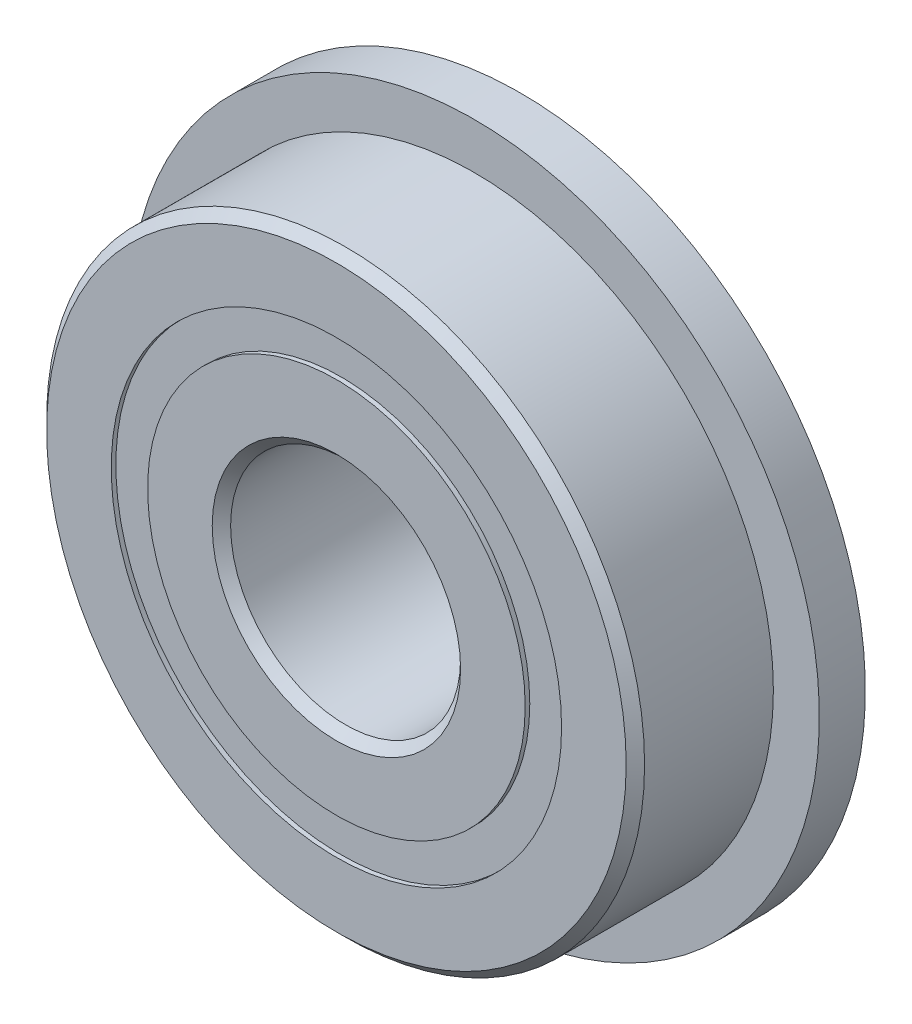
from build123d import *

# Parameters (mm, degrees)
CIRPATTERN1_COUNT = 12
SKETCH5_W         = 0.927052779
SKETCH5_H         = 0.791208792
SKETCH6_W         = 1
SKETCH6_H         = 2.604395604


with BuildPart() as part:
    # Sketch1 → Revolve1 (revolve)
    with BuildSketch(Plane(origin=(0, 0, 0), x_dir=(0, 0, -1), z_dir=(1, 0, 0))):
        with BuildLine():
            Line((1.8, 6.5), (-1.8, 6.5))
            Line((-1.8, 6.5), (-2, 6.3))
            Line((-2, 6.3), (-2, 4.895604396))
            Line((-2, 4.895604396), (-0.888888889, 4.895604396))
            ThreePointArc((-0.888888889, 4.895604396), (0, 5.472947221), (0.888888889, 4.895604396))
            Line((0.888888889, 4.895604396), (2, 4.895604396))
            Line((2, 4.895604396), (2, 6.3))
            Line((2, 6.3), (1.8, 6.5))
        make_face()
    revolve(axis=Axis((0, 0, 2), (0, 0, -1)))

    # Sketch6 → Revolve6 (revolve)
    with BuildSketch(Plane(origin=(0, 0, 0), x_dir=(0, 0, -1), z_dir=(1, 0, 0))):
        with Locations((1.5, 6.197802198)):
            Rectangle(SKETCH6_W, SKETCH6_H)
    revolve(axis=Axis((0, 0, -2), (0, 0, 1)))


with BuildPart() as body_2:
    # Sketch3 → Revolve3 (revolve)
    with BuildSketch(Plane(origin=(0, 0, 0), x_dir=(0, 0, -1), z_dir=(1, 0, 0))):
        with BuildLine():
            Line((-2, 4.104395604), (-0.888888889, 4.104395604))
            ThreePointArc((-0.888888889, 4.104395604), (0, 3.527052779), (0.888888889, 4.104395604))
            Line((0.888888889, 4.104395604), (2, 4.104395604))
            Line((2, 4.104395604), (2, 2.7))
            Line((2, 2.7), (1.8, 2.5))
            Line((1.8, 2.5), (-1.8, 2.5))
            Line((-1.8, 2.5), (-2, 2.7))
            Line((-2, 2.7), (-2, 4.104395604))
        make_face()
    revolve(axis=Axis((0, 0, 2), (0, 0, -1)))


with BuildPart() as body_3:
    # Sketch4 → Revolve4 (revolve)
    with BuildSketch(Plane(origin=(0, 0, 0), x_dir=(0, 0, -1), z_dir=(1, 0, 0))):
        with BuildLine():
            Line((-0.972947221, 4.5), (0.972947221, 4.5))
            ThreePointArc((0.972947221, 4.5), (0, 5.472947221), (-0.972947221, 4.5))
        make_face()
    revolve(axis=Axis((0, 4.5, 0.972947221), (0, 0, -1)))


with BuildPart() as cirpattern1_1:
    # CirPattern1: pattern copy
    add(body_3.part.rotate(Axis((0, 0, 0), (0, 0, 1)), 1 * 360 / CIRPATTERN1_COUNT))


with BuildPart() as cirpattern1_2:
    # CirPattern1: pattern copy
    add(body_3.part.rotate(Axis((0, 0, 0), (0, 0, 1)), 2 * 360 / CIRPATTERN1_COUNT))


with BuildPart() as cirpattern1_3:
    # CirPattern1: pattern copy
    add(body_3.part.rotate(Axis((0, 0, 0), (0, 0, 1)), 3 * 360 / CIRPATTERN1_COUNT))


with BuildPart() as cirpattern1_4:
    # CirPattern1: pattern copy
    add(body_3.part.rotate(Axis((0, 0, 0), (0, 0, 1)), 4 * 360 / CIRPATTERN1_COUNT))


with BuildPart() as cirpattern1_5:
    # CirPattern1: pattern copy
    add(body_3.part.rotate(Axis((0, 0, 0), (0, 0, 1)), 5 * 360 / CIRPATTERN1_COUNT))


with BuildPart() as cirpattern1_6:
    # CirPattern1: pattern copy
    add(body_3.part.rotate(Axis((0, 0, 0), (0, 0, 1)), 6 * 360 / CIRPATTERN1_COUNT))


with BuildPart() as cirpattern1_7:
    # CirPattern1: pattern copy
    add(body_3.part.rotate(Axis((0, 0, 0), (0, 0, 1)), 7 * 360 / CIRPATTERN1_COUNT))


with BuildPart() as cirpattern1_8:
    # CirPattern1: pattern copy
    add(body_3.part.rotate(Axis((0, 0, 0), (0, 0, 1)), 8 * 360 / CIRPATTERN1_COUNT))


with BuildPart() as cirpattern1_9:
    # CirPattern1: pattern copy
    add(body_3.part.rotate(Axis((0, 0, 0), (0, 0, 1)), 9 * 360 / CIRPATTERN1_COUNT))


with BuildPart() as cirpattern1_10:
    # CirPattern1: pattern copy
    add(body_3.part.rotate(Axis((0, 0, 0), (0, 0, 1)), 10 * 360 / CIRPATTERN1_COUNT))


with BuildPart() as cirpattern1_11:
    # CirPattern1: pattern copy
    add(body_3.part.rotate(Axis((0, 0, 0), (0, 0, 1)), 11 * 360 / CIRPATTERN1_COUNT))


with BuildPart() as body_15:
    # Sketch5 → Revolve5 (revolve)
    with BuildSketch(Plane(origin=(0, 0, 0), x_dir=(0, 0, -1), z_dir=(1, 0, 0))):
        with Locations((-1.436473611, 4.5)):
            Rectangle(SKETCH5_W, SKETCH5_H)
        with Locations((1.436473611, 4.5)):
            Rectangle(SKETCH5_W, SKETCH5_H)
    revolve(axis=Axis((0, 0, 2), (0, 0, -1)))


solid = Compound([part.part, body_2.part, body_3.part, cirpattern1_1.part, cirpattern1_2.part, cirpattern1_3.part, cirpattern1_4.part, cirpattern1_5.part, cirpattern1_6.part, cirpattern1_7.part, cirpattern1_8.part, cirpattern1_9.part, cirpattern1_10.part, cirpattern1_11.part, body_15.part])
